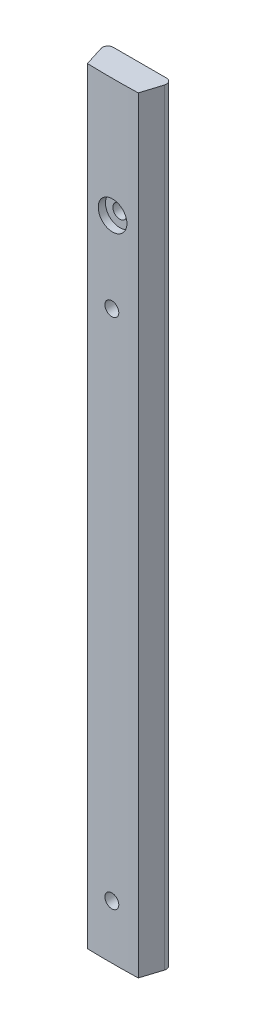
from build123d import *

# Parameters (mm, degrees)
BOSS_EXTRUDE4_DEPTH                                 = 180.34
CBORE_FOR_4_BINDING_HEAD_MACHINE_SCREW1_D           = 3.2639
CBORE_FOR_4_BINDING_HEAD_MACHINE_SCREW1_CBORE_D     = 6.74624
CBORE_FOR_4_BINDING_HEAD_MACHINE_SCREW1_CBORE_DEPTH = 1.7272
FILLET1_R                                           = 1.27
CBORE_FOR_4_BINDING_HEAD_MACHINE_SCREW2_D           = 3.2639
CBORE_FOR_4_BINDING_HEAD_MACHINE_SCREW2_CBORE_D     = 6.74624
CBORE_FOR_4_BINDING_HEAD_MACHINE_SCREW2_CBORE_DEPTH = 1.7272


with BuildPart() as part:
    # Sketch5 → Boss-Extrude4 (new body)
    with BuildSketch(Plane(origin=(0, 0, 0), x_dir=(1, 0, 0), z_dir=(0, 1, 0))):
        with BuildLine():
            Line((0, 0), (15.9512, 0))
            Line((15.9512, 0), (13.9573, -6.35))
            ThreePointArc((13.9573, -6.35), (7.9756, -6.438062229), (1.9939, -6.35))
            Line((1.9939, -6.35), (0, 0))
        make_face()
    extrude(amount=BOSS_EXTRUDE4_DEPTH)

    # CBORE for #4 Binding Head Machine Screw1 (through all)
    with Locations(Plane(origin=(0, 0, 0), x_dir=(-1, 0, 0), z_dir=(0, 0, -1))):
        with Locations((-7.827128231, 133.35), (-7.827128231, 12.7)):
            CounterBoreHole(CBORE_FOR_4_BINDING_HEAD_MACHINE_SCREW1_D / 2, CBORE_FOR_4_BINDING_HEAD_MACHINE_SCREW1_CBORE_D / 2, CBORE_FOR_4_BINDING_HEAD_MACHINE_SCREW1_CBORE_DEPTH)

    # Fillet1
    fillet1_edges = [part.edges().sort_by_distance(p)[0] for p in [
        (0, 90.17, 0),
        (15.9512, 90.17, 0),
    ]]
    fillet(fillet1_edges, radius=FILLET1_R)

    # CBORE for #4 Binding Head Machine Screw2 (through all)
    with Locations(Plane(origin=(7.9756, 152.424464219, 6.438062229), x_dir=(1, 0, 0), z_dir=(0, 0, 1))):
        with Locations((0, 0)):
            CounterBoreHole(CBORE_FOR_4_BINDING_HEAD_MACHINE_SCREW2_D / 2, CBORE_FOR_4_BINDING_HEAD_MACHINE_SCREW2_CBORE_D / 2, CBORE_FOR_4_BINDING_HEAD_MACHINE_SCREW2_CBORE_DEPTH)


solid = part.part
